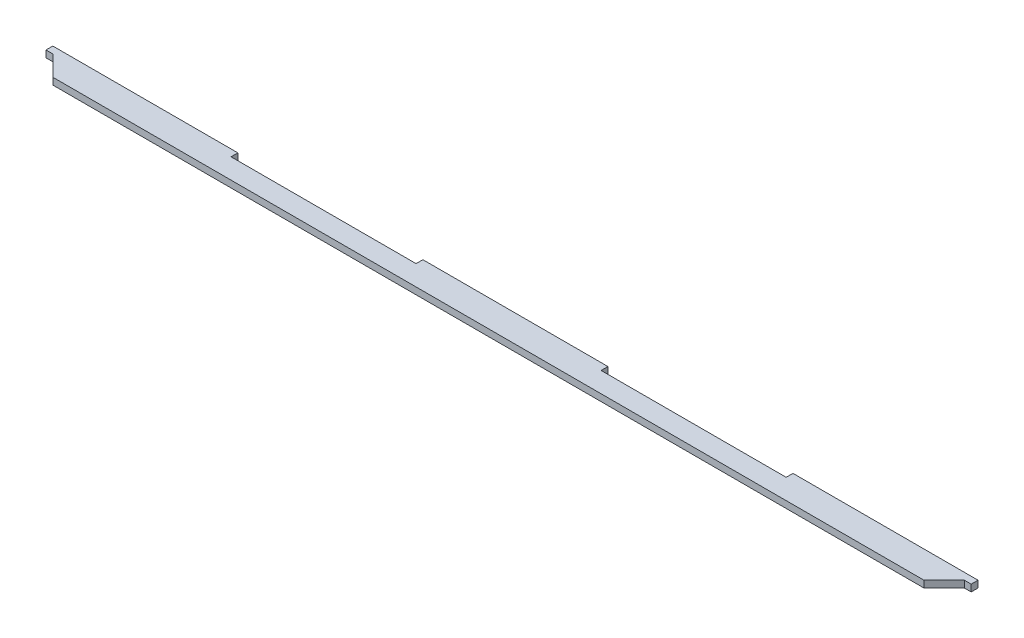
from build123d import *

# Parameters (mm, degrees)
BOSS_EXTRUDE1_DEPTH = 2.7


with BuildPart() as part:
    # Sketch1 → Boss-Extrude1 (new body)
    with BuildSketch(Plane(origin=(0, 0, 0), x_dir=(1, 0, 0), z_dir=(0, 1, 0))):
        Polygon((-183.2, 2.405591569), (-180.5, 2.405591569), (-172.5, -5.594408431), (172.5, -5.594408431), (180.5, 2.405591569), (183.2, 2.405591569), (183.2, 5.105591569), (109.92, 5.105591569), (109.92, 2.405591569), (36.64, 2.405591569), (36.64, 5.105591569), (-36.64, 5.105591569), (-36.64, 2.405591569), (-109.92, 2.405591569), (-109.92, 5.105591569), (-183.2, 5.105591569), align=None)
    extrude(amount=BOSS_EXTRUDE1_DEPTH)


solid = part.part
